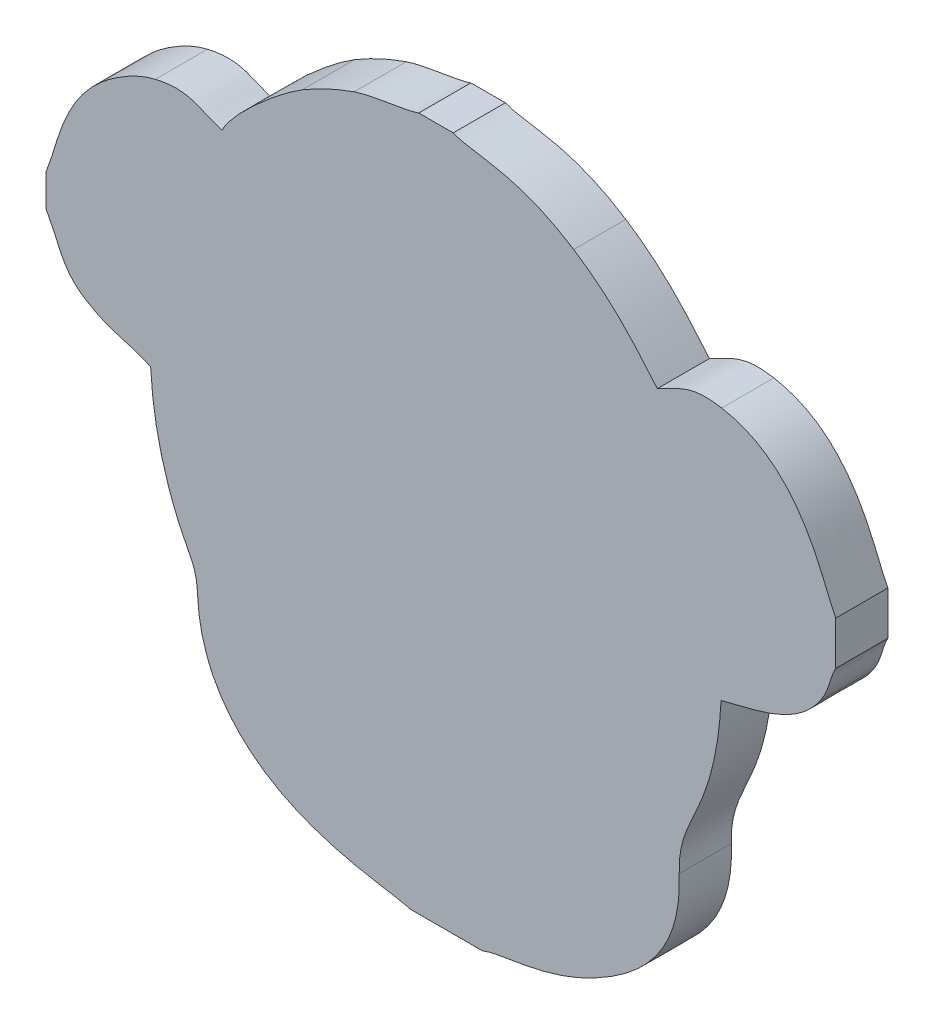
from build123d import *

# Parameters (mm, degrees)
BOSS_EXTRUDE1_DEPTH = 3


with BuildPart() as part:
    # Model → Boss-Extrude1 (new body)
    with BuildSketch(Plane.XY):
        with BuildLine():
            Line((55.1272, 105.2165), (55.1272, 103.3338))
            add(Edge.make_bspline(
                [(55.1272, 103.3338), (55.9357, 101.875), (56.0272, 100.8916), (57.2517, 100.0613)],
                knots=[0.038461538, 0.038461538, 0.038461538, 0.038461538, 0.076923077, 0.076923077, 0.076923077, 0.076923077], degree=3))
            add(Edge.make_bspline(
                [(57.2517, 100.0613), (58.7272, 99.0608), (59.7559, 99.1354), (61.1406, 98.4843)],
                knots=[0.076923077, 0.076923077, 0.076923077, 0.076923077, 0.115384615, 0.115384615, 0.115384615, 0.115384615], degree=3))
            add(Edge.make_bspline(
                [(61.1406, 98.4843), (61.2643, 95.9602), (61.838, 93.6047), (62.7653, 91.5083)],
                knots=[0.115384615, 0.115384615, 0.115384615, 0.115384615, 0.153846154, 0.153846154, 0.153846154, 0.153846154], degree=3))
            add(Edge.make_bspline(
                [(62.7653, 91.5083), (63.3171, 90.261), (63.7888, 89.9265), (63.8434, 88.4315)],
                knots=[0.153846154, 0.153846154, 0.153846154, 0.153846154, 0.192307692, 0.192307692, 0.192307692, 0.192307692], degree=3))
            add(Edge.make_bspline(
                [(63.8434, 88.4315), (63.8899, 87.1583), (64.224, 85.8877), (64.7219, 84.8986)],
                knots=[0.192307692, 0.192307692, 0.192307692, 0.192307692, 0.230769231, 0.230769231, 0.230769231, 0.230769231], degree=3))
            add(Edge.make_bspline(
                [(64.7219, 84.8986), (67.4566, 79.4661), (74.7931, 79.4131), (76.0211, 78.9235)],
                knots=[0.230769231, 0.230769231, 0.230769231, 0.230769231, 0.269230769, 0.269230769, 0.269230769, 0.269230769], degree=3))
            Line((76.0211, 78.9235), (80.2468, 78.9235))
            add(Edge.make_bspline(
                [(80.2468, 78.9235), (81.4396, 79.4171), (83.7679, 79.2274), (86.7105, 80.8069)],
                knots=[0.307692308, 0.307692308, 0.307692308, 0.307692308, 0.346153846, 0.346153846, 0.346153846, 0.346153846], degree=3))
            add(Edge.make_bspline(
                [(86.7105, 80.8069), (89.8776, 82.5068), (91.6976, 84.7693), (91.5598, 88.4331)],
                knots=[0.346153846, 0.346153846, 0.346153846, 0.346153846, 0.384615385, 0.384615385, 0.384615385, 0.384615385], degree=3))
            add(Edge.make_bspline(
                [(91.5598, 88.4331), (91.4432, 91.536), (93.6274, 92.0439), (93.9689, 98.2668)],
                knots=[0.384615385, 0.384615385, 0.384615385, 0.384615385, 0.423076923, 0.423076923, 0.423076923, 0.423076923], degree=3))
            add(Edge.make_bspline(
                [(93.9689, 98.2668), (96.0863, 98.8396), (98.2608, 99.0994), (99.6714, 101.1074)],
                knots=[0.423076923, 0.423076923, 0.423076923, 0.423076923, 0.461538462, 0.461538462, 0.461538462, 0.461538462], degree=3))
            add(Edge.make_bspline(
                [(99.6714, 101.1074), (100.2485, 101.9289), (100.1784, 102.4641), (100.5659, 103.1647)],
                knots=[0.461538462, 0.461538462, 0.461538462, 0.461538462, 0.5, 0.5, 0.5, 0.5], degree=3))
            Line((100.5659, 103.1647), (100.5659, 105.6703))
            add(Edge.make_bspline(
                [(100.5659, 105.6703), (99.7223, 107.2591), (98.5859, 112.0519), (94.0061, 112.8642)],
                knots=[0.538461538, 0.538461538, 0.538461538, 0.538461538, 0.576923077, 0.576923077, 0.576923077, 0.576923077], degree=3))
            add(Edge.make_bspline(
                [(94.0061, 112.8642), (92.18, 113.1882), (91.4848, 112.5304), (90.2994, 111.974)],
                knots=[0.576923077, 0.576923077, 0.576923077, 0.576923077, 0.615384615, 0.615384615, 0.615384615, 0.615384615], degree=3))
            add(Edge.make_bspline(
                [(90.2994, 111.974), (88.7995, 113.7706), (87.5152, 115.1976), (85.4874, 116.5045)],
                knots=[0.615384615, 0.615384615, 0.615384615, 0.615384615, 0.653846154, 0.653846154, 0.653846154, 0.653846154], degree=3))
            add(Edge.make_bspline(
                [(85.4874, 116.5045), (82.1232, 118.6728), (79.9482, 118.2978), (78.5521, 118.8487)],
                knots=[0.653846154, 0.653846154, 0.653846154, 0.653846154, 0.692307692, 0.692307692, 0.692307692, 0.692307692], degree=3))
            Line((78.5521, 118.8487), (76.5707, 118.8487))
            add(Edge.make_bspline(
                [(76.5707, 118.8487), (75.9147, 118.5898), (73.949, 118.4167), (72.8515, 118.0451)],
                knots=[0.730769231, 0.730769231, 0.730769231, 0.730769231, 0.769230769, 0.769230769, 0.769230769, 0.769230769], degree=3))
            add(Edge.make_bspline(
                [(72.8515, 118.0451), (71.807, 117.6915), (70.6758, 117.1447), (69.865, 116.6538)],
                knots=[0.769230769, 0.769230769, 0.769230769, 0.769230769, 0.807692308, 0.807692308, 0.807692308, 0.807692308], degree=3))
            add(Edge.make_bspline(
                [(69.865, 116.6538), (68.5207, 115.84), (65.7355, 113.4696), (65.2526, 112.3186)],
                knots=[0.807692308, 0.807692308, 0.807692308, 0.807692308, 0.846153846, 0.846153846, 0.846153846, 0.846153846], degree=3))
            add(Edge.make_bspline(
                [(65.2526, 112.3186), (63.7751, 112.8048), (63.3732, 113.3887), (61.4119, 112.9491)],
                knots=[0.846153846, 0.846153846, 0.846153846, 0.846153846, 0.884615385, 0.884615385, 0.884615385, 0.884615385], degree=3))
            add(Edge.make_bspline(
                [(61.4119, 112.9491), (60.2523, 112.6892), (59.0201, 111.8593), (58.3253, 111.2712)],
                knots=[0.884615385, 0.884615385, 0.884615385, 0.884615385, 0.923076923, 0.923076923, 0.923076923, 0.923076923], degree=3))
            add(Edge.make_bspline(
                [(58.3253, 111.2712), (56.0021, 109.3047), (55.7198, 106.5647), (55.1272, 105.2165)],
                knots=[0.923076923, 0.923076923, 0.923076923, 0.923076923, 1, 1, 1, 1], degree=3))
        make_face()
    extrude(amount=BOSS_EXTRUDE1_DEPTH)


solid = part.part
